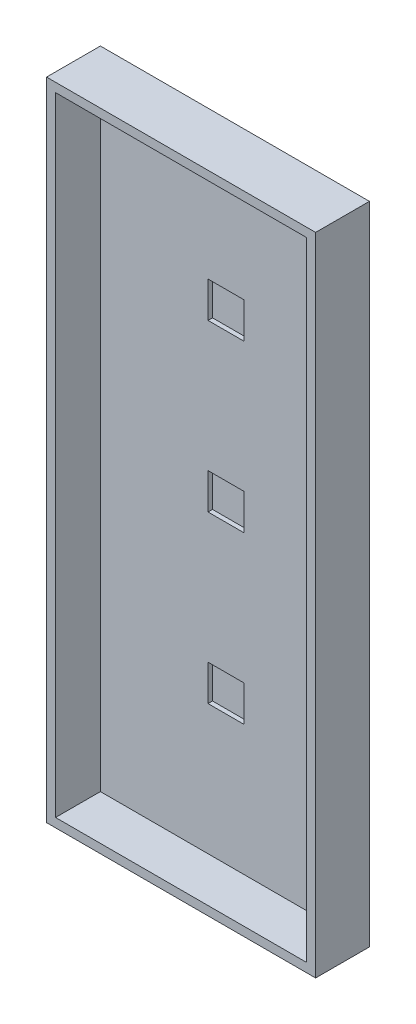
from build123d import *

# Parameters (mm, degrees)
SKETCH1_W           = 762
SKETCH1_H           = 1828.8
BOSS_EXTRUDE1_DEPTH = 152.4
SKETCH2_W           = 711.2
SKETCH2_H           = 1778
CUT_EXTRUDE3_DEPTH  = 127
SKETCH10_W          = 101.6
SKETCH10_H          = 101.6
CUT_EXTRUDE4_DEPTH  = 12.7


with BuildPart() as part:
    # Sketch1 → Boss-Extrude1 (new body)
    with BuildSketch(Plane.XY):
        with Locations((-1498.701019621, -163.505851304)):
            Rectangle(SKETCH1_W, SKETCH1_H)
    extrude(amount=BOSS_EXTRUDE1_DEPTH)

    # Sketch2 → Cut-Extrude3 (cut)
    with BuildSketch(Plane.XY.offset(152.4)):
        with Locations((-1498.701019621, -163.505851304)):
            Rectangle(SKETCH2_W, SKETCH2_H)
    extrude(amount=-CUT_EXTRUDE3_DEPTH, mode=Mode.SUBTRACT)

    # Sketch10 → Cut-Extrude4 (cut)
    with BuildSketch(Plane.XY.offset(25.4)):
        with Locations((-1498.701019621, 306.394148696)):
            Rectangle(SKETCH10_W, SKETCH10_H)
        with Locations((-1498.701019621, -163.505851304)):
            Rectangle(SKETCH10_W, SKETCH10_H)
        with Locations((-1498.701019621, -633.405851304)):
            Rectangle(SKETCH10_W, SKETCH10_H)
    extrude(amount=-CUT_EXTRUDE4_DEPTH, mode=Mode.SUBTRACT)


solid = part.part
